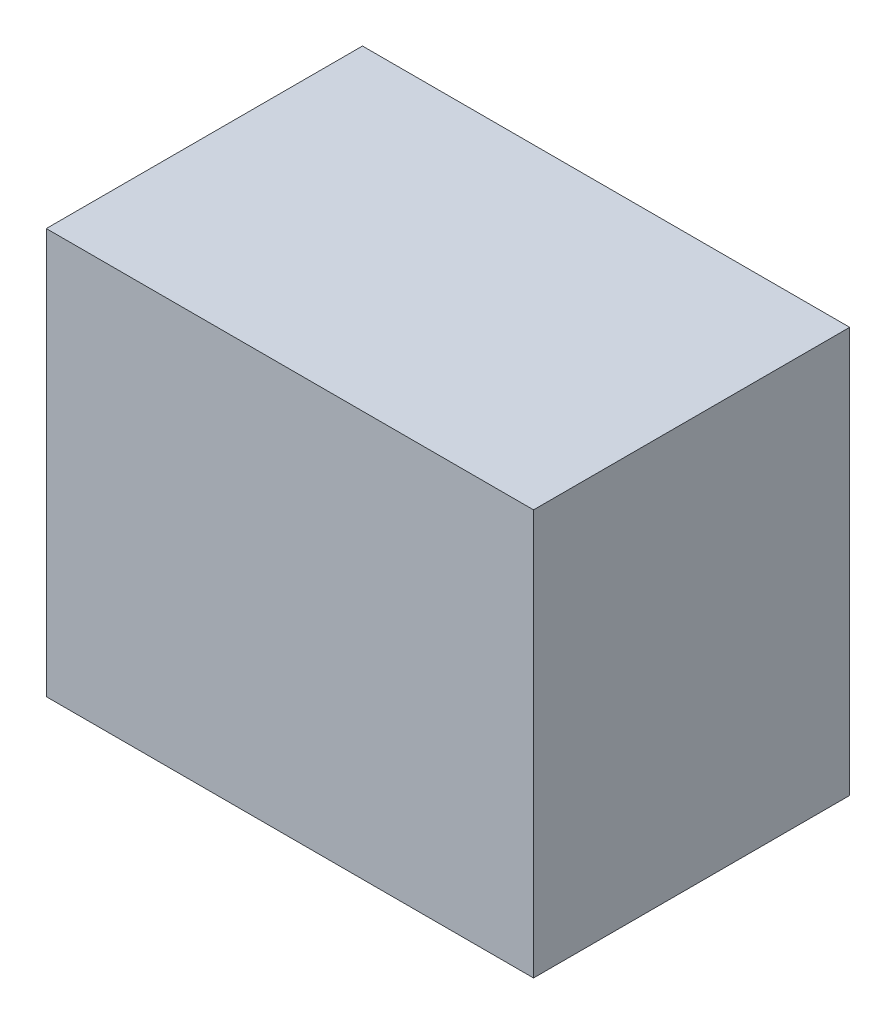
from build123d import *

# Parameters (mm, degrees)
SKETCH2_W           = 47.772038396
SKETCH2_H           = 39.750614038
BOSS_EXTRUDE1_DEPTH = 31


with BuildPart() as part:
    # Sketch2 → Boss-Extrude1 (new body)
    with BuildSketch(Plane.XY):
        with Locations((8.556185981, -4.099839116)):
            Rectangle(SKETCH2_W, SKETCH2_H)
    extrude(amount=BOSS_EXTRUDE1_DEPTH)


solid = part.part
